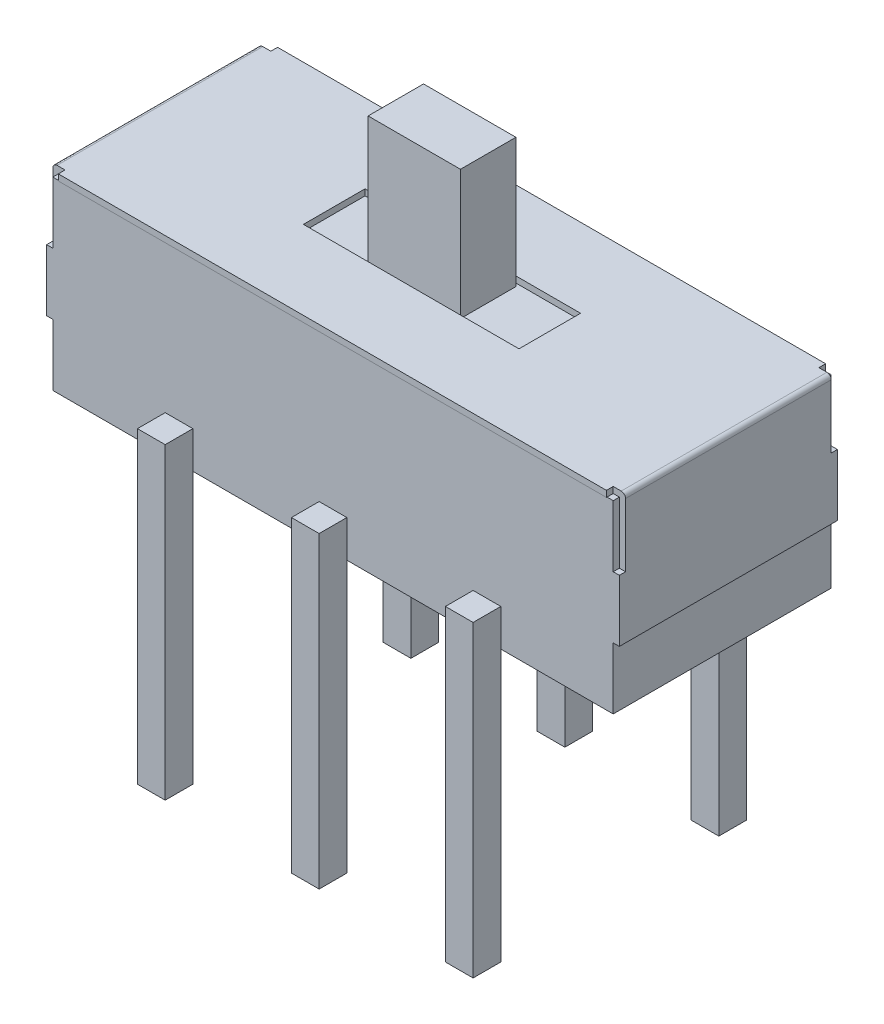
from build123d import *

# Parameters (mm, degrees)
ESQUISSE1_W             = 9.1
ESQUISSE1_H             = 3
BOSS_EXTRU_1_DEPTH      = 1.77
BOSS_EXTRU_1_DEPTH_BACK = 1.77
ESQUISSE2_W             = 3.5
ESQUISSE2_H             = 1
BOSS_EXTRU_2_DEPTH      = 0.1
BOSS_EXTRU_3_DEPTH      = 0.1
CONG_1_R                = 0.07
ESQUISSE4_W             = 1.5
ESQUISSE4_H             = 0.9
BOSS_EXTRU_4_DEPTH      = 2.1
ESQUISSE6_W             = 0.45
ESQUISSE6_H             = 5.1
BOSS_EXTRU_5_DEPTH      = 0.45
CHANFREIN1_SIZE         = 0.1


with BuildPart() as part:
    # Esquisse1 → Boss.-Extru.1 (new body, two sides)
    with BuildSketch(Plane.XY) as boss_extru_1_sk:
        with Locations((0, 1.5)):
            Rectangle(ESQUISSE1_W, ESQUISSE1_H)
    extrude(amount=BOSS_EXTRU_1_DEPTH)
    extrude(boss_extru_1_sk.sketch, amount=-BOSS_EXTRU_1_DEPTH_BACK)

    # Esquisse2 → Boss.-Extru.2 (add)
    with BuildSketch(Plane(origin=(0, 3, 0), x_dir=(1, 0, 0), z_dir=(0, 1, 0))):
        Polygon((-4.65, 1.67), (-4.65, -1.67), (-4.45, -1.67), (-4.45, -1.78), (4.45, -1.78), (4.45, -1.67), (4.65, -1.67), (4.65, 1.67), (4.45, 1.67), (4.45, 1.78), (-4.45, 1.78), (-4.45, 1.67), align=None)
        Rectangle(ESQUISSE2_W, ESQUISSE2_H, mode=Mode.SUBTRACT)
    extrude(amount=BOSS_EXTRU_2_DEPTH)

    # Esquisse3 → Boss.-Extru.3 (add)
    with BuildSketch(Plane.ZY.offset(4.55)):
        Polygon((-1.77, 1), (1.77, 1), (1.77, 2), (1.67, 2), (1.67, 3), (-1.67, 3), (-1.67, 2), (-1.77, 2), align=None)
    boss_extru_3 = extrude(amount=BOSS_EXTRU_3_DEPTH)

    # Sym_trie1: Boss.-Extru.3 across plane
    add(boss_extru_3.mirror(Plane(origin=(0, 0, 0), x_dir=(0, 0, 1), z_dir=(1, 0, 0))))

    # Cong_1
    cong_1_edges = [part.edges().sort_by_distance(p)[0] for p in [
        (-4.65, 3.1, 0),
        (4.65, 3.1, 0),
    ]]
    fillet(cong_1_edges, radius=CONG_1_R)

    # Esquisse4 → Boss.-Extru.4 (add)
    with BuildSketch(Plane(origin=(0, 3, 0), x_dir=(1, 0, 0), z_dir=(0, 1, 0))):
        Rectangle(ESQUISSE4_W, ESQUISSE4_H)
    extrude(amount=BOSS_EXTRU_4_DEPTH)

    # Esquisse6 → Boss.-Extru.5 (add)
    with BuildSketch(Plane(origin=(0, 0, -1.77), x_dir=(-1, 0, 0), z_dir=(0, 0, -1))):
        with Locations((0, -1.95)):
            Rectangle(ESQUISSE6_W, ESQUISSE6_H)
        with Locations((-2.5, -1.95)):
            Rectangle(ESQUISSE6_W, ESQUISSE6_H)
        with Locations((2.5, -1.95)):
            Rectangle(ESQUISSE6_W, ESQUISSE6_H)
    boss_extru_5 = extrude(amount=BOSS_EXTRU_5_DEPTH)

    # Sym_trie2: Boss.-Extru.5 across plane
    add(boss_extru_5.mirror(Plane.XY))

    # Chanfrein1
    chanfrein1_edges = [part.edges().sort_by_distance(p)[0] for p in [
        (-0.225, -4.5, -1.995),
        (0, -4.5, -1.77),
        (0.225, -4.5, -1.995),
        (0, -4.5, -2.22),
        (2.275, -4.5, -1.995),
        (2.5, -4.5, -1.77),
        (2.725, -4.5, -1.995),
        (2.5, -4.5, -2.22),
        (-2.5, -4.5, -1.77),
        (-2.275, -4.5, -1.995),
        (-2.725, -4.5, -1.995),
        (-2.5, -4.5, -2.22),
        (0, -4.5, 2.22),
        (-0.225, -4.5, 1.995),
        (0.225, -4.5, 1.995),
        (0, -4.5, 1.77),
        (2.5, -4.5, 2.22),
        (2.275, -4.5, 1.995),
        (2.725, -4.5, 1.995),
        (2.5, -4.5, 1.77),
        (-2.275, -4.5, 1.995),
        (-2.5, -4.5, 2.22),
        (-2.725, -4.5, 1.995),
        (-2.5, -4.5, 1.77),
    ]]
    chamfer(chanfrein1_edges, length=CHANFREIN1_SIZE)


solid = part.part
